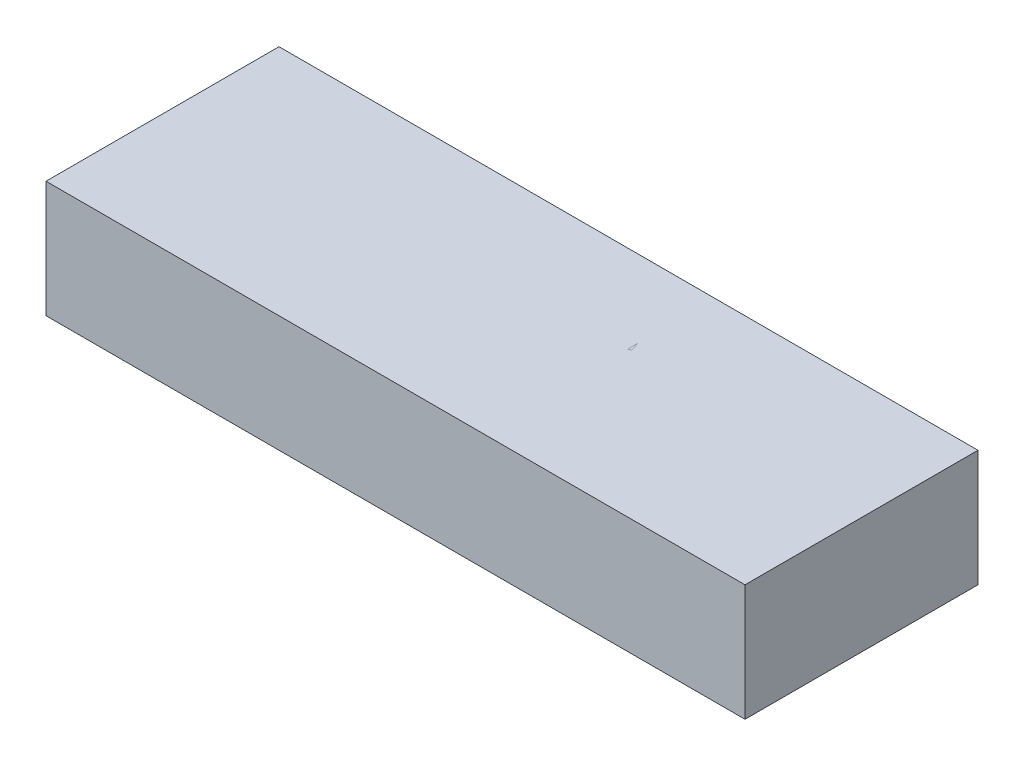
from build123d import *

# Parameters (mm, degrees)
SKETCH1_W             = 38.1
SKETCH1_H             = 12.7
BOSS_EXTRUDE1_DEPTH   = 6.35
BOSS_EXTRUDE2_DEPTH   = 0.508
BOSS_EXTRUDE2_2_DEPTH = 0.508
BOSS_EXTRUDE2_3_DEPTH = 0.508
BOSS_EXTRUDE2_4_DEPTH = 0.508
BOSS_EXTRUDE2_5_DEPTH = 0.508
BOSS_EXTRUDE2_6_DEPTH = 0.508


with BuildPart() as part:
    # Sketch1 → Boss-Extrude1 (new body)
    with BuildSketch(Plane(origin=(0, 0, 0), x_dir=(1, 0, 0), z_dir=(0, 1, 0))):
        Rectangle(SKETCH1_W, SKETCH1_H)
    extrude(amount=BOSS_EXTRUDE1_DEPTH)


with BuildPart() as body_2:
    # Sketch2 → Boss-Extrude2 (new body)
    with BuildSketch(Plane(origin=(0, 6.35, 0), x_dir=(1, 0, 0), z_dir=(0, 1, 0))):
        Polygon((-12.522431526, 2.146065762), (-11.733769667, 2.146065762), (-10.767870896, -0.80675208), (-9.795187936, 2.146065762), (-9.014158289, 2.146065762), (-8.298426451, -2.087267571), (-9.06758377, -2.087267571), (-9.519580298, 0.586550538), (-10.399828695, -2.087267571), (-11.141001238, -2.087267571), (-12.016161494, 0.586550538), (-12.467309998, -2.087267571), (-13.23731534, -2.087267571), align=None)
    extrude(amount=-BOSS_EXTRUDE2_DEPTH)


with BuildPart() as body_3:
    # Sketch2 → Boss-Extrude2 2 (new body)
    with BuildSketch(Plane(origin=(0, 6.35, 0), x_dir=(1, 0, 0), z_dir=(0, 1, 0))):
        with BuildLine():
            add(Edge.make_bspline(
                [(-5.603407755, 2.254612771), (-5.529806067, 2.252707091), (-5.384499664, 2.248944848), (-5.17080638, 2.217583617), (-4.96487339, 2.166484986), (-4.766793816, 2.095454193), (-4.577063625, 2.002567364), (-4.395013576, 1.8904579), (-4.221295764, 1.757009803), (-4.057690309, 1.605336197), (-3.906489362, 1.440397773), (-3.775473653, 1.262812236), (-3.663748263, 1.077181005), (-3.571149961, 0.883006677), (-3.500619118, 0.678944501), (-3.451124709, 0.466034924), (-3.419327003, 0.244338519), (-3.415669777, 0.093393484), (-3.413811067, 0.016678743)],
                knots=[0, 0, 0, 0, 0.000220721, 0.000435753, 0.000646365, 0.000856403, 0.00106576, 0.001278984, 0.001496765, 0.001721811, 0.001947536, 0.002167008, 0.002382688, 0.002596632, 0.002811184, 0.003029014, 0.003251603, 0.003481643, 0.003481643, 0.003481643, 0.003481643], degree=3))
            add(Edge.make_bspline(
                [(-3.413811067, 0.016678743), (-3.415790513, -0.0591716), (-3.419691075, -0.208637134), (-3.449826587, -0.42829052), (-3.500154489, -0.638919392), (-3.569489073, -0.841000511), (-3.660407992, -1.033555067), (-3.769954615, -1.217812494), (-3.90101967, -1.392062839), (-4.048822699, -1.556212592), (-4.211541007, -1.705213715), (-4.383885526, -1.836520698), (-4.565060476, -1.94778528), (-4.754800675, -2.038956497), (-4.95351301, -2.10971112), (-5.16070664, -2.159633649), (-5.376368742, -2.189972577), (-5.52302943, -2.193847661), (-5.59747159, -2.19581458)],
                knots=[0, 0, 0, 0, 0.000227498, 0.000448292, 0.000663647, 0.000876318, 0.001088005, 0.001301358, 0.001518283, 0.001741042, 0.001963118, 0.002179197, 0.002390088, 0.002599839, 0.002809591, 0.003021648, 0.003238241, 0.003461503, 0.003461503, 0.003461503, 0.003461503], degree=3))
            add(Edge.make_bspline(
                [(-5.59747159, -2.19581458), (-5.675329164, -2.194050157), (-5.828308655, -2.190583307), (-6.052194825, -2.157615148), (-6.266697121, -2.107953584), (-6.470013601, -2.033836364), (-6.664214868, -1.941183606), (-6.84787407, -1.82707618), (-7.020929484, -1.691702657), (-7.182388437, -1.538530004), (-7.32867064, -1.370925525), (-7.457793377, -1.193866256), (-7.56671127, -1.008704774), (-7.655428304, -0.81535442), (-7.72536925, -0.615016819), (-7.774704641, -0.406471856), (-7.803848233, -0.1902197), (-7.807907766, -0.043336912), (-7.809964913, 0.031095143)],
                knots=[0, 0, 0, 0, 0.000233428, 0.000458655, 0.000677506, 0.000892905, 0.001106449, 0.001322007, 0.001540154, 0.0017645, 0.001988669, 0.002206638, 0.002421018, 0.00263199, 0.002843861, 0.003056544, 0.003273863, 0.003497125, 0.003497125, 0.003497125, 0.003497125], degree=3))
            add(Edge.make_bspline(
                [(-7.809964913, 0.031095143), (-7.809319262, 0.081169133), (-7.808036135, 0.180683061), (-7.792579523, 0.328157623), (-7.770326445, 0.47275368), (-7.737415198, 0.613894725), (-7.697436445, 0.752576442), (-7.645638323, 0.887507948), (-7.586678043, 1.020130682), (-7.517788507, 1.148878203), (-7.441190004, 1.272565928), (-7.357614217, 1.390610398), (-7.266850996, 1.501584285), (-7.16919272, 1.606216862), (-7.064302845, 1.703820373), (-6.953561089, 1.79577653), (-6.834819707, 1.879642652), (-6.710677575, 1.957466916), (-6.581834577, 2.027842048), (-6.448815223, 2.087743256), (-6.314359972, 2.140053961), (-6.176672685, 2.181339882), (-6.037228925, 2.214966832), (-5.894539019, 2.237204912), (-5.749892088, 2.252661096), (-5.652351745, 2.253960669), (-5.603407755, 2.254612771)],
                knots=[0, 0, 0, 0, 0.00015016, 0.000298419, 0.00044439, 0.000588803, 0.000732899, 0.000877016, 0.001022016, 0.001168075, 0.001314688, 0.001458222, 0.001601661, 0.001744456, 0.001887252, 0.002031229, 0.002175945, 0.002323006, 0.002470616, 0.002615965, 0.002760383, 0.002903098, 0.003046877, 0.003190336, 0.003336063, 0.003482832, 0.003482832, 0.003482832, 0.003482832], degree=3))
        make_face()
        with BuildLine():
            add(Edge.make_bspline(
                [(-5.615280084, 1.494783711), (-5.66481401, 1.493454604), (-5.762574159, 1.49083148), (-5.905970494, 1.470846821), (-6.04363604, 1.438929048), (-6.174807662, 1.392696545), (-6.300053869, 1.333854302), (-6.419596684, 1.262607922), (-6.531780686, 1.176508389), (-6.638101741, 1.080178004), (-6.734145319, 0.972843817), (-6.819002849, 0.857816981), (-6.890014935, 0.73528959), (-6.949488001, 0.606399894), (-6.994258039, 0.469698562), (-7.026146395, 0.326256391), (-7.046298645, 0.175826223), (-7.048838861, 0.073278173), (-7.050135853, 0.02091886)],
                knots=[0, 0, 0, 0, 0.000148559, 0.000293196, 0.000433479, 0.000571871, 0.00070958, 0.000848034, 0.000988469, 0.001133133, 0.001277857, 0.001419824, 0.001561198, 0.001701985, 0.001844919, 0.001991813, 0.002142335, 0.002299366, 0.002299366, 0.002299366, 0.002299366], degree=3))
            add(Edge.make_bspline(
                [(-7.050135853, 0.02091886), (-7.04841624, -0.037107036), (-7.045046083, -0.150828179), (-7.021333251, -0.316721518), (-6.980762956, -0.473391311), (-6.922180239, -0.620071311), (-6.8495223, -0.758390289), (-6.759292671, -0.886652949), (-6.652952646, -1.005627268), (-6.571029151, -1.075089431), (-6.529449421, -1.110344494)],
                knots=[0, 0, 0, 0, 0.000174052, 0.000341112, 0.00050155, 0.000658395, 0.000813933, 0.000969205, 0.001127733, 0.001291118, 0.001291118, 0.001291118, 0.001291118], degree=3))
            add(Edge.make_bspline(
                [(-6.529449421, -1.110344494), (-6.495387685, -1.136389581), (-6.428031628, -1.187892954), (-6.320516696, -1.253905093), (-6.209797487, -1.310484081), (-6.095038486, -1.356199233), (-5.976482057, -1.392158004), (-5.854144458, -1.41733934), (-5.728199032, -1.433142806), (-5.643028832, -1.43503162), (-5.600015661, -1.43598552)],
                knots=[0, 0, 0, 0, 0.000128564, 0.000254232, 0.000377869, 0.000501171, 0.00062431, 0.000749047, 0.00087548, 0.00100448, 0.00100448, 0.00100448, 0.00100448], degree=3))
            add(Edge.make_bspline(
                [(-5.600015661, -1.43598552), (-5.551333471, -1.434645144), (-5.455549733, -1.432007912), (-5.314822798, -1.412269275), (-5.18000212, -1.378864375), (-5.050250721, -1.333037439), (-4.925942746, -1.273456381), (-4.807685722, -1.200000161), (-4.695272312, -1.113570728), (-4.589086709, -1.015975314), (-4.492028048, -0.908218304), (-4.407347598, -0.792577927), (-4.334077683, -0.671602087), (-4.27584136, -0.543578553), (-4.229302559, -0.409715809), (-4.197797996, -0.269421004), (-4.177475505, -0.123272487), (-4.174934573, -0.023813257), (-4.173640127, 0.026855025)],
                knots=[0, 0, 0, 0, 0.000146018, 0.000287294, 0.000425304, 0.000562096, 0.000699402, 0.000838015, 0.000978963, 0.0011242, 0.001270122, 0.001413275, 0.001553619, 0.001693636, 0.001834431, 0.001978017, 0.002124335, 0.002276283, 0.002276283, 0.002276283, 0.002276283], degree=3))
            add(Edge.make_bspline(
                [(-4.173640127, 0.026855025), (-4.174979361, 0.07723195), (-4.17761544, 0.176391245), (-4.197388818, 0.322164015), (-4.230581874, 0.461839459), (-4.276546423, 0.595645683), (-4.335240718, 0.723713866), (-4.407822168, 0.845593644), (-4.494036094, 0.961167191), (-4.591898288, 1.069646915), (-4.698415271, 1.169332833), (-4.812771895, 1.255842089), (-4.931768334, 1.331015882), (-5.058134947, 1.389903996), (-5.189286378, 1.436820031), (-5.32602292, 1.471369673), (-5.468862472, 1.490691087), (-5.566039172, 1.493407343), (-5.615280084, 1.494783711)],
                knots=[0, 0, 0, 0, 0.000151101, 0.000297418, 0.000440373, 0.000581168, 0.000721184, 0.000862257, 0.001005914, 0.001153033, 0.001300045, 0.001442855, 0.001582635, 0.001721473, 0.001860148, 0.002000007, 0.002143804, 0.002291516, 0.002291516, 0.002291516, 0.002291516], degree=3))
        make_face(mode=Mode.SUBTRACT)
    extrude(amount=-BOSS_EXTRUDE2_2_DEPTH)


with BuildPart() as body_4:
    # Sketch2 → Boss-Extrude2 3 (new body)
    with BuildSketch(Plane(origin=(0, 6.35, 0), x_dir=(1, 0, 0), z_dir=(0, 1, 0))):
        Polygon((-3.088170041, 2.146065762), (-0.808682862, 2.146065762), (-0.808682862, 1.386236702), (-1.568511921, 1.386236702), (-1.568511921, -2.087267571), (-2.328340981, -2.087267571), (-2.328340981, 1.386236702), (-3.088170041, 1.386236702), align=None)
    extrude(amount=-BOSS_EXTRUDE2_3_DEPTH)


with BuildPart() as body_5:
    # Sketch2 → Boss-Extrude2 4 (new body)
    with BuildSketch(Plane(origin=(0, 6.35, 0), x_dir=(1, 0, 0), z_dir=(0, 1, 0))):
        with BuildLine():
            add(Edge.make_bspline(
                [(1.777788826, 2.254612771), (1.851390515, 2.252707091), (1.996696918, 2.248944848), (2.210390201, 2.217583617), (2.416323191, 2.166484986), (2.614402766, 2.095454193), (2.804132956, 2.002567364), (2.986183005, 1.8904579), (3.159900817, 1.757009803), (3.323506272, 1.605336197), (3.474707219, 1.440397773), (3.605722928, 1.262812236), (3.717448318, 1.077181005), (3.810046621, 0.883006677), (3.880577463, 0.678944501), (3.930071873, 0.466034924), (3.961869579, 0.244338519), (3.965526804, 0.093393484), (3.967385514, 0.016678743)],
                knots=[0, 0, 0, 0, 0.000220721, 0.000435753, 0.000646365, 0.000856403, 0.00106576, 0.001278984, 0.001496765, 0.001721811, 0.001947536, 0.002167008, 0.002382688, 0.002596632, 0.002811184, 0.003029014, 0.003251603, 0.003481643, 0.003481643, 0.003481643, 0.003481643], degree=3))
            add(Edge.make_bspline(
                [(3.967385514, 0.016678743), (3.965406068, -0.0591716), (3.961505506, -0.208637134), (3.931369994, -0.42829052), (3.881042093, -0.638919392), (3.811707508, -0.841000511), (3.720788589, -1.033555067), (3.611241966, -1.217812494), (3.480176911, -1.392062839), (3.332373882, -1.556212592), (3.169655575, -1.705213715), (2.997311055, -1.836520698), (2.816136105, -1.94778528), (2.626395907, -2.038956497), (2.427683571, -2.10971112), (2.220489941, -2.159633649), (2.004827839, -2.189972577), (1.858167152, -2.193847661), (1.783724991, -2.19581458)],
                knots=[0, 0, 0, 0, 0.000227498, 0.000448292, 0.000663647, 0.000876318, 0.001088005, 0.001301358, 0.001518283, 0.001741042, 0.001963118, 0.002179197, 0.002390088, 0.002599839, 0.002809591, 0.003021648, 0.003238241, 0.003461503, 0.003461503, 0.003461503, 0.003461503], degree=3))
            add(Edge.make_bspline(
                [(1.783724991, -2.19581458), (1.705867417, -2.194050157), (1.552887926, -2.190583307), (1.329001756, -2.157615148), (1.11449946, -2.107953584), (0.911182981, -2.033836364), (0.716981713, -1.941183606), (0.533322511, -1.82707618), (0.360267097, -1.691702657), (0.198808144, -1.538530004), (0.052525941, -1.370925525), (-0.076596796, -1.193866256), (-0.185514689, -1.008704774), (-0.274231723, -0.81535442), (-0.344172669, -0.615016819), (-0.39350806, -0.406471856), (-0.422651652, -0.1902197), (-0.426711185, -0.043336912), (-0.428768332, 0.031095143)],
                knots=[0, 0, 0, 0, 0.000233428, 0.000458655, 0.000677506, 0.000892905, 0.001106449, 0.001322007, 0.001540154, 0.0017645, 0.001988669, 0.002206638, 0.002421018, 0.00263199, 0.002843861, 0.003056544, 0.003273863, 0.003497125, 0.003497125, 0.003497125, 0.003497125], degree=3))
            add(Edge.make_bspline(
                [(-0.428768332, 0.031095143), (-0.428122681, 0.081169133), (-0.426839554, 0.180683061), (-0.411382941, 0.328157623), (-0.389129863, 0.47275368), (-0.356218617, 0.613894725), (-0.316239864, 0.752576442), (-0.264441742, 0.887507948), (-0.205481462, 1.020130682), (-0.136591926, 1.148878203), (-0.059993422, 1.272565928), (0.023582364, 1.390610398), (0.114345585, 1.501584285), (0.212003861, 1.606216862), (0.316893736, 1.703820373), (0.427635492, 1.79577653), (0.546376874, 1.879642652), (0.670519006, 1.957466916), (0.799362004, 2.027842048), (0.932381359, 2.087743256), (1.066836609, 2.140053961), (1.204523896, 2.181339882), (1.343967656, 2.214966832), (1.486657562, 2.237204912), (1.631304493, 2.252661096), (1.728844836, 2.253960669), (1.777788826, 2.254612771)],
                knots=[0, 0, 0, 0, 0.00015016, 0.000298419, 0.00044439, 0.000588803, 0.000732899, 0.000877016, 0.001022016, 0.001168075, 0.001314688, 0.001458222, 0.001601661, 0.001744456, 0.001887252, 0.002031229, 0.002175945, 0.002323006, 0.002470616, 0.002615965, 0.002760383, 0.002903098, 0.003046877, 0.003190336, 0.003336063, 0.003482832, 0.003482832, 0.003482832, 0.003482832], degree=3))
        make_face()
        with BuildLine():
            add(Edge.make_bspline(
                [(1.765916497, 1.494783711), (1.716382571, 1.493454604), (1.618622422, 1.49083148), (1.475226087, 1.470846821), (1.337560541, 1.438929048), (1.206388919, 1.392696545), (1.081142712, 1.333854302), (0.961599897, 1.262607922), (0.849415895, 1.176508389), (0.74309484, 1.080178004), (0.647051262, 0.972843817), (0.562193732, 0.857816981), (0.491181646, 0.73528959), (0.43170858, 0.606399894), (0.386938542, 0.469698562), (0.355050187, 0.326256391), (0.334897936, 0.175826223), (0.33235772, 0.073278173), (0.331060728, 0.02091886)],
                knots=[0, 0, 0, 0, 0.000148559, 0.000293196, 0.000433479, 0.000571871, 0.00070958, 0.000848034, 0.000988469, 0.001133133, 0.001277857, 0.001419824, 0.001561198, 0.001701985, 0.001844919, 0.001991813, 0.002142335, 0.002299366, 0.002299366, 0.002299366, 0.002299366], degree=3))
            add(Edge.make_bspline(
                [(0.331060728, 0.02091886), (0.332780341, -0.037107036), (0.336150498, -0.150828179), (0.35986333, -0.316721518), (0.400433625, -0.473391311), (0.459016342, -0.620071311), (0.531674281, -0.758390289), (0.62190391, -0.886652949), (0.728243936, -1.005627268), (0.81016743, -1.075089431), (0.85174716, -1.110344494)],
                knots=[0, 0, 0, 0, 0.000174052, 0.000341112, 0.00050155, 0.000658395, 0.000813933, 0.000969205, 0.001127733, 0.001291118, 0.001291118, 0.001291118, 0.001291118], degree=3))
            add(Edge.make_bspline(
                [(0.85174716, -1.110344494), (0.885808897, -1.136389581), (0.953164954, -1.187892954), (1.060679885, -1.253905093), (1.171399094, -1.310484081), (1.286158096, -1.356199233), (1.404714524, -1.392158004), (1.527052123, -1.41733934), (1.652997549, -1.433142806), (1.738167749, -1.43503162), (1.78118092, -1.43598552)],
                knots=[0, 0, 0, 0, 0.000128564, 0.000254232, 0.000377869, 0.000501171, 0.00062431, 0.000749047, 0.00087548, 0.00100448, 0.00100448, 0.00100448, 0.00100448], degree=3))
            add(Edge.make_bspline(
                [(1.78118092, -1.43598552), (1.82986311, -1.434645144), (1.925646848, -1.432007912), (2.066373783, -1.412269275), (2.201194461, -1.378864375), (2.33094586, -1.333037439), (2.455253835, -1.273456381), (2.573510859, -1.200000161), (2.685924269, -1.113570728), (2.792109872, -1.015975314), (2.889168533, -0.908218304), (2.973848983, -0.792577927), (3.047118898, -0.671602087), (3.105355221, -0.543578553), (3.151894022, -0.409715809), (3.183398585, -0.269421004), (3.203721076, -0.123272487), (3.206262008, -0.023813257), (3.207556455, 0.026855025)],
                knots=[0, 0, 0, 0, 0.000146018, 0.000287294, 0.000425304, 0.000562096, 0.000699402, 0.000838015, 0.000978963, 0.0011242, 0.001270122, 0.001413275, 0.001553619, 0.001693636, 0.001834431, 0.001978017, 0.002124335, 0.002276283, 0.002276283, 0.002276283, 0.002276283], degree=3))
            add(Edge.make_bspline(
                [(3.207556455, 0.026855025), (3.20621722, 0.07723195), (3.203581141, 0.176391245), (3.183807763, 0.322164015), (3.150614707, 0.461839459), (3.104650158, 0.595645683), (3.045955863, 0.723713866), (2.973374413, 0.845593644), (2.887160487, 0.961167191), (2.789298293, 1.069646915), (2.68278131, 1.169332833), (2.568424686, 1.255842089), (2.449428247, 1.331015882), (2.323061634, 1.389903996), (2.191910204, 1.436820031), (2.055173661, 1.471369673), (1.912334109, 1.490691087), (1.815157409, 1.493407343), (1.765916497, 1.494783711)],
                knots=[0, 0, 0, 0, 0.000151101, 0.000297418, 0.000440373, 0.000581168, 0.000721184, 0.000862257, 0.001005914, 0.001153033, 0.001300045, 0.001442855, 0.001582635, 0.001721473, 0.001860148, 0.002000007, 0.002143804, 0.002291516, 0.002291516, 0.002291516, 0.002291516], degree=3))
        make_face(mode=Mode.SUBTRACT)
    extrude(amount=-BOSS_EXTRUDE2_4_DEPTH)


with BuildPart() as body_6:
    # Sketch2 → Boss-Extrude2 5 (new body)
    with BuildSketch(Plane(origin=(0, 6.35, 0), x_dir=(1, 0, 0), z_dir=(0, 1, 0))):
        with BuildLine():
            Line((4.727214574, 2.146065762), (5.612551113, 2.146065762))
            add(Edge.make_bspline(
                [(5.612551113, 2.146065762), (5.671071588, 2.145858048), (5.783622948, 2.145458555), (5.94591586, 2.139155618), (6.095004219, 2.130384564), (6.231108763, 2.116999702), (6.354171265, 2.099252994), (6.464315062, 2.078332561), (6.561536934, 2.054489243), (6.646656815, 2.024778587), (6.723473298, 1.991265418), (6.795076939, 1.952758172), (6.863047422, 1.909685639), (6.926930438, 1.860914466), (6.987281144, 1.807322032), (7.044213395, 1.748854393), (7.096922688, 1.685015766), (7.145082642, 1.61620953), (7.188976564, 1.543826948), (7.227769585, 1.467768639), (7.259316134, 1.387981707), (7.287190892, 1.305619247), (7.307268177, 1.219503872), (7.321231635, 1.130473929), (7.331455133, 1.038216024), (7.332042935, 0.975540099), (7.332342779, 0.943568433)],
                knots=[0, 0, 0, 0, 0.000175549, 0.00033763, 0.000487174, 0.000623534, 0.00074778, 0.000860044, 0.000959797, 0.001047763, 0.001130165, 0.001210977, 0.001291432, 0.001371318, 0.001451813, 0.001533373, 0.001615893, 0.001699886, 0.001785112, 0.001869685, 0.001955666, 0.002042285, 0.00213032, 0.002220522, 0.002312582, 0.002408443, 0.002408443, 0.002408443, 0.002408443], degree=3))
            add(Edge.make_bspline(
                [(7.332342779, 0.943568433), (7.331563892, 0.910197358), (7.330036635, 0.844762763), (7.32181, 0.74864468), (7.306774296, 0.65668562), (7.284000534, 0.56915483), (7.257825053, 0.484962887), (7.223018378, 0.405663184), (7.183735605, 0.330102422), (7.137080603, 0.259349437), (7.085879017, 0.191832663), (7.02633265, 0.130138919), (6.962299192, 0.0709524), (6.890179088, 0.017980348), (6.81315146, -0.032359015), (6.72968585, -0.077979884), (6.640326983, -0.120029063), (6.577503275, -0.143478589), (6.545376967, -0.155470028)],
                knots=[0, 0, 0, 0, 0.000100124, 0.000196325, 0.000289175, 0.000379262, 0.000467493, 0.000553344, 0.000638696, 0.000722668, 0.000807309, 0.000892492, 0.000979541, 0.001068584, 0.001160554, 0.001255442, 0.001353703, 0.001456538, 0.001456538, 0.001456538, 0.001456538], degree=3))
            Line((6.545376967, -0.155470028), (7.522300044, -2.087267571))
            Line((7.522300044, -2.087267571), (6.677668634, -2.087267571))
            Line((6.677668634, -2.087267571), (5.744842779, -0.241968426))
            Line((5.744842779, -0.241968426), (5.487043634, -0.241968426))
            Line((5.487043634, -0.241968426), (5.487043634, -2.087267571))
            Line((5.487043634, -2.087267571), (4.727214574, -2.087267571))
            Line((4.727214574, -2.087267571), (4.727214574, 2.146065762))
        make_face()
        with BuildLine():
            Line((5.487043634, 0.517860634), (5.783003837, 0.517860634))
            add(Edge.make_bspline(
                [(5.783003837, 0.517860634), (5.819187432, 0.518268158), (5.888471242, 0.519048479), (5.98811046, 0.52266793), (6.078606632, 0.53138902), (6.16034838, 0.54240779), (6.233747021, 0.555130552), (6.298147865, 0.573363043), (6.354543231, 0.592899618), (6.40226483, 0.617178513), (6.443037069, 0.644788882), (6.478241287, 0.676154948), (6.507360223, 0.712457175), (6.531326593, 0.752709026), (6.549969823, 0.797266518), (6.563577952, 0.845640511), (6.571182884, 0.898382047), (6.572057858, 0.934780888), (6.57251372, 0.953744715)],
                knots=[0, 0, 0, 0, 0.00010856, 0.00020787, 0.000299003, 0.000381157, 0.000455338, 0.000522203, 0.000581758, 0.000634096, 0.000682314, 0.000729148, 0.000774972, 0.000821366, 0.000869248, 0.000919453, 0.000971743, 0.001028617, 0.001028617, 0.001028617, 0.001028617], degree=3))
            add(Edge.make_bspline(
                [(6.57251372, 0.953744715), (6.571651871, 0.976180307), (6.569958929, 1.020250869), (6.553159687, 1.083697025), (6.526418921, 1.142420784), (6.489764656, 1.196156816), (6.443603375, 1.243265532), (6.390629663, 1.284792239), (6.329700219, 1.317628453), (6.273284139, 1.339286869), (6.221958692, 1.352245324), (6.175639097, 1.361901849), (6.122000726, 1.368745706), (6.061003086, 1.376004834), (5.992801662, 1.380712011), (5.917024715, 1.384147312), (5.833889877, 1.385552863), (5.775936999, 1.386002193), (5.745690803, 1.386236702)],
                knots=[0, 0, 0, 0, 6.7187e-05, 0.000131976, 0.000195351, 0.000260035, 0.000326007, 0.000392499, 0.000461195, 0.000532856, 0.000573171, 0.000619905, 0.000674712, 0.000735303, 0.000804181, 0.000879731, 0.000962855, 0.001053597, 0.001053597, 0.001053597, 0.001053597], degree=3))
            Line((5.745690803, 1.386236702), (5.487043634, 1.386236702))
            Line((5.487043634, 1.386236702), (5.487043634, 0.517860634))
        make_face(mode=Mode.SUBTRACT)
    extrude(amount=-BOSS_EXTRUDE2_5_DEPTH)


with BuildPart() as body_7:
    # Sketch2 → Boss-Extrude2 6 (new body)
    with BuildSketch(Plane(origin=(0, 6.35, 0), x_dir=(1, 0, 0), z_dir=(0, 1, 0))):
        Polygon((10.228343047, 2.146065762), (11.4028556, 2.146065762), (11.4028556, -2.087267571), (10.64302654, -2.087267571), (10.64302654, 1.440510207), (9.774650472, 1.440510207), align=None)
    extrude(amount=-BOSS_EXTRUDE2_6_DEPTH)


solid = Compound([part.part, body_2.part, body_3.part, body_4.part, body_5.part, body_6.part, body_7.part])
